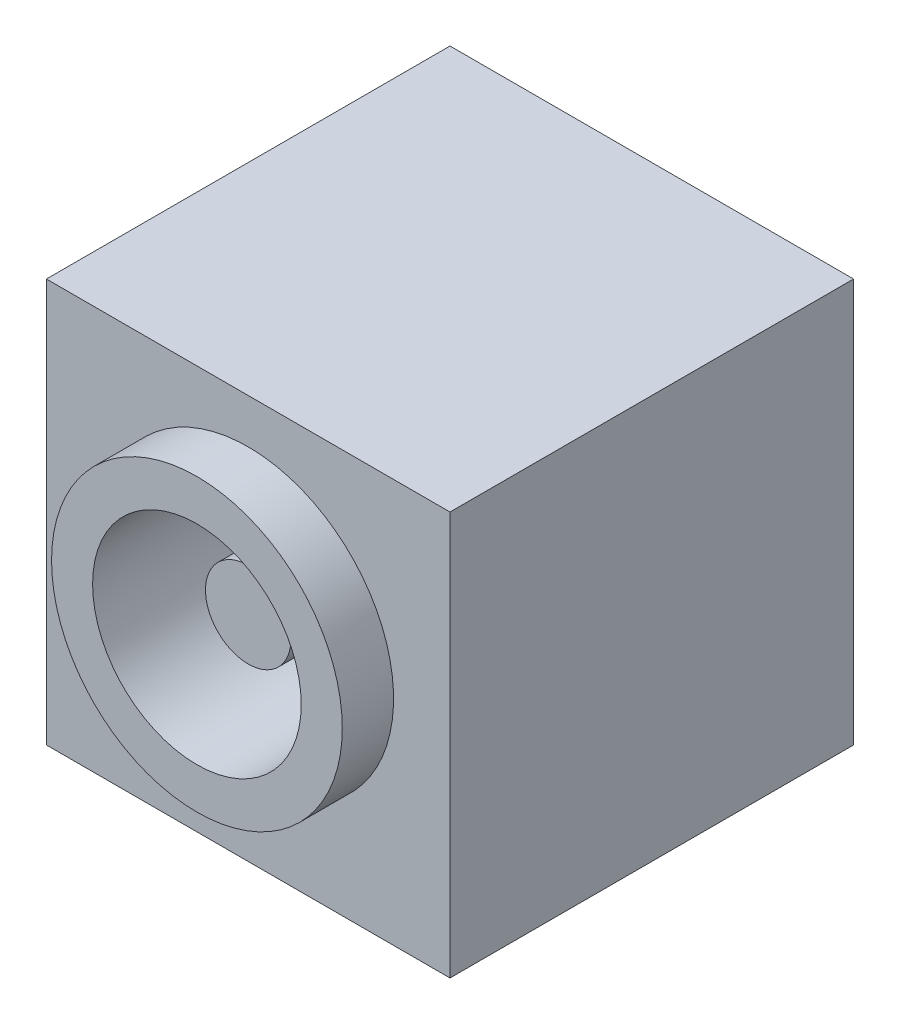
from build123d import *

# Parameters (mm, degrees)
SKETCH1_W           = 11.8
SKETCH1_H           = 11.8
BOSS_EXTRUDE1_DEPTH = 11.8
SKETCH2_R           = 4.25
BOSS_EXTRUDE2_DEPTH = 1.5
SKETCH3_R           = 3.05
CUT_EXTRUDE1_DEPTH  = 9.5
SKETCH4_R           = 1.25
BOSS_EXTRUDE3_DEPTH = 8


with BuildPart() as part:
    # Sketch1 → Boss-Extrude1 (new body)
    with BuildSketch(Plane(origin=(0, 0, 0), x_dir=(1, 0, 0), z_dir=(0, 1, 0))):
        with Locations((5.9, 5.9)):
            Rectangle(SKETCH1_W, SKETCH1_H)
    extrude(amount=BOSS_EXTRUDE1_DEPTH)

    # Sketch2 → Boss-Extrude2 (add)
    with BuildSketch(Plane.XY):
        with Locations((5.9, 6.25)):
            Circle(SKETCH2_R)
    extrude(amount=BOSS_EXTRUDE2_DEPTH)

    # Sketch3 → Cut-Extrude1 (cut)
    with BuildSketch(Plane.XY.offset(1.5)):
        with Locations((5.9, 6.25)):
            Circle(SKETCH3_R)
    extrude(amount=-CUT_EXTRUDE1_DEPTH, mode=Mode.SUBTRACT)

    # Sketch4 → Boss-Extrude3 (add)
    with BuildSketch(Plane.XY.offset(-8)):
        with Locations((5.9, 6.25)):
            Circle(SKETCH4_R)
    extrude(amount=BOSS_EXTRUDE3_DEPTH)


solid = part.part
